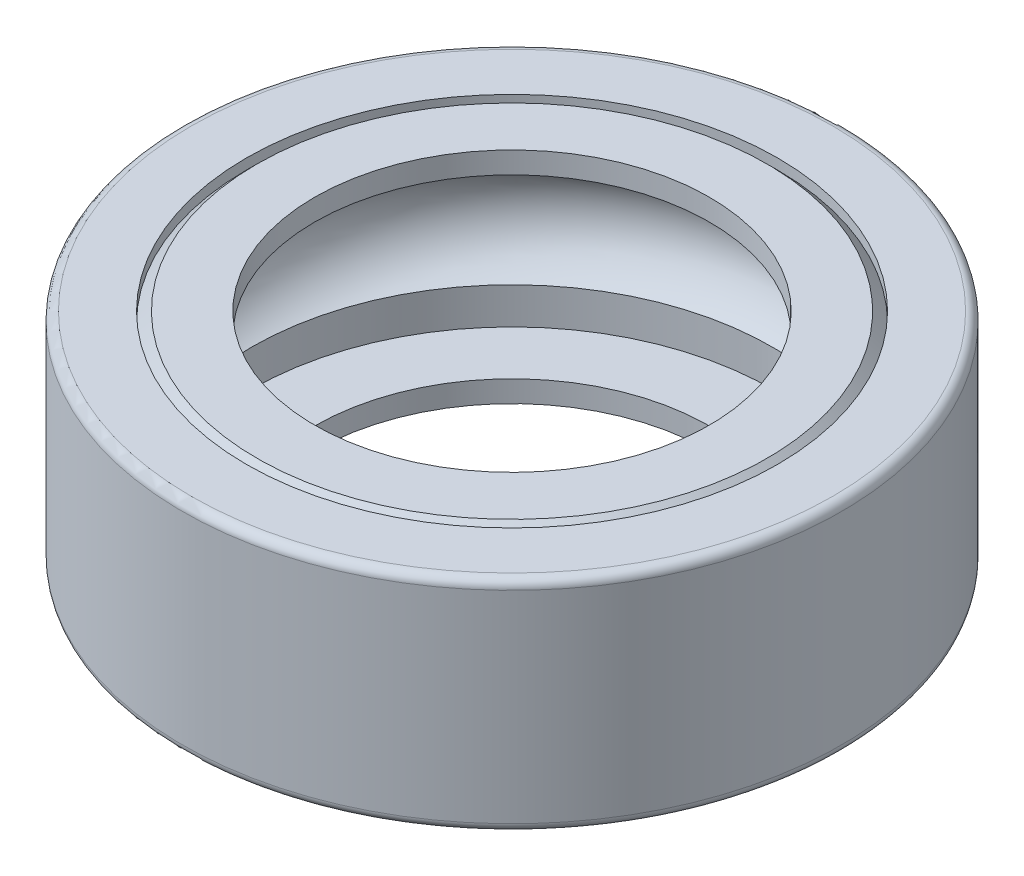
from build123d import *


with BuildPart() as part:
    # Sketch1 → Revolve1 (revolve)
    with BuildSketch(Plane(origin=(0, 0, 0), x_dir=(-1, 0, 0), z_dir=(0, 0, -1))):
        with BuildLine():
            Line((-5.925, -4.5), (-5.925, -3.669134295))
            ThreePointArc((-5.925, -3.669134295), (-6.6, -2.5), (-5.925, -1.330865705))
            Line((-5.925, -1.330865705), (-5.925, -0.5))
            Line((-5.925, -0.5), (-6.0435, -0.5))
            Line((-6.0435, -0.5), (-6.0435, -0.49))
            Line((-6.0435, -0.49), (-4.4935, -0.49))
            Line((-4.4935, -0.49), (-4.4935, 0))
            Line((-4.4935, 0), (-5.8035, 0))
            Line((-5.8035, 0), (-6.0435, -0.24))
            Line((-6.0435, -0.24), (-6.0435, 0))
            Line((-6.0435, 0), (-7.3, 0))
            ThreePointArc((-7.3, 0), (-7.441421356, -0.058578644), (-7.5, -0.2))
            Line((-7.5, -0.2), (-7.5, -4.8))
            ThreePointArc((-7.5, -4.8), (-7.441421356, -4.941421356), (-7.3, -5))
            Line((-7.3, -5), (-6.0435, -5))
            Line((-6.0435, -5), (-6.0435, -4.76))
            Line((-6.0435, -4.76), (-5.8035, -5))
            Line((-5.8035, -5), (-4.4935, -5))
            Line((-4.4935, -5), (-4.4935, -4.51))
            Line((-4.4935, -4.51), (-6.0435, -4.51))
            Line((-6.0435, -4.51), (-6.0435, -4.5))
            Line((-6.0435, -4.5), (-5.925, -4.5))
        make_face()
    revolve(axis=Axis((0, -5.001250002, 0), (0, 1, 0)))


solid = part.part
